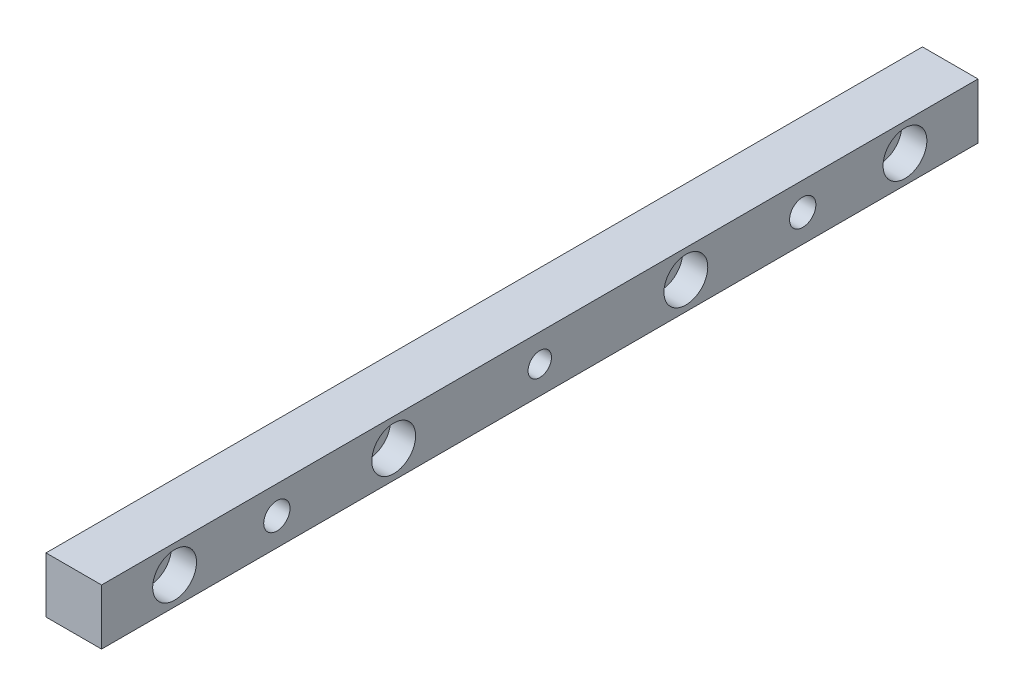
from build123d import *

# Parameters (mm, degrees)
ESBO_O1_W                                            = 300
ESBO_O1_H                                            = 19.02
ESBO_O1_R                                            = 4
RESSALTO_EXTRUS_O1_DEPTH                             = 19.02
REBAIXO_PARA_PARAFUSO_ALLEN_SEXTAVADO_DE_D           = 9
REBAIXO_PARA_PARAFUSO_ALLEN_SEXTAVADO_DE_CBORE_D     = 15
REBAIXO_PARA_PARAFUSO_ALLEN_SEXTAVADO_DE_CBORE_DEPTH = 8.6
ESBO_O5_R                                            = 4
CORTE_EXTRUS_O1_DEPTH                                = 20.02
REBAIXO_PARA_PARAFUSO_ALLEN_SEXTAVAD_2_D             = 9
REBAIXO_PARA_PARAFUSO_ALLEN_SEXTAVAD_2_CBORE_D       = 15
REBAIXO_PARA_PARAFUSO_ALLEN_SEXTAVAD_2_CBORE_DEPTH   = 8.6
ESBO_O11_R                                           = 7.5
CORTE_EXTRUS_O2_DEPTH                                = 8.6


with BuildPart() as part:
    # Esboço1 → Ressalto-extrusão1 (new body)
    with BuildSketch(Plane(origin=(0, 0, 0), x_dir=(0, 0, -1), z_dir=(1, 0, 0))):
        with Locations((0, 3.19)):
            Rectangle(ESBO_O1_W, ESBO_O1_H)
        with Locations((-50, 3.19)):
            Circle(ESBO_O1_R, mode=Mode.SUBTRACT)
        with Locations((-125, 3.19)):
            Circle(ESBO_O1_R, mode=Mode.SUBTRACT)
        with Locations((50, 3.19)):
            Circle(ESBO_O1_R, mode=Mode.SUBTRACT)
        with Locations((125, 3.19)):
            Circle(ESBO_O1_R, mode=Mode.SUBTRACT)
    extrude(amount=RESSALTO_EXTRUS_O1_DEPTH)

    # Rebaixo para parafuso Allen sextavado de (through all)
    with Locations(Plane(origin=(19.02, 3.19, 125), x_dir=(0, 0, 1), z_dir=(1, 0, 0))):
        with Locations((0, 0), (-75, 0), (-175, 0), (-250, 0)):
            CounterBoreHole(REBAIXO_PARA_PARAFUSO_ALLEN_SEXTAVADO_DE_D / 2, REBAIXO_PARA_PARAFUSO_ALLEN_SEXTAVADO_DE_CBORE_D / 2, REBAIXO_PARA_PARAFUSO_ALLEN_SEXTAVADO_DE_CBORE_DEPTH)

    # Esboço5 → Corte-extrusão1 (cut, through all)
    with BuildSketch(Plane.ZY):
        with Locations((0, 3.19)):
            Circle(ESBO_O5_R)
        with Locations((90, 3.19)):
            Circle(ESBO_O5_R)
        with Locations((-90, 3.19)):
            Circle(ESBO_O5_R)
    extrude(amount=-CORTE_EXTRUS_O1_DEPTH, mode=Mode.SUBTRACT)

    # Rebaixo para parafuso Allen sextavad 2 (through all)
    with Locations(Plane(origin=(0, 3.19, -90), x_dir=(0, 0, -1), z_dir=(-1, 0, 0))):
        with Locations((0, 0), (-180, 0)):
            CounterBoreHole(REBAIXO_PARA_PARAFUSO_ALLEN_SEXTAVAD_2_D / 2, REBAIXO_PARA_PARAFUSO_ALLEN_SEXTAVAD_2_CBORE_D / 2, REBAIXO_PARA_PARAFUSO_ALLEN_SEXTAVAD_2_CBORE_DEPTH)

    # Esboço11 → Corte-extrusão2 (cut)
    with BuildSketch(Plane.ZY):
        with Locations((0, 3.19)):
            Circle(ESBO_O11_R)
    extrude(amount=-CORTE_EXTRUS_O2_DEPTH, mode=Mode.SUBTRACT)


solid = part.part
